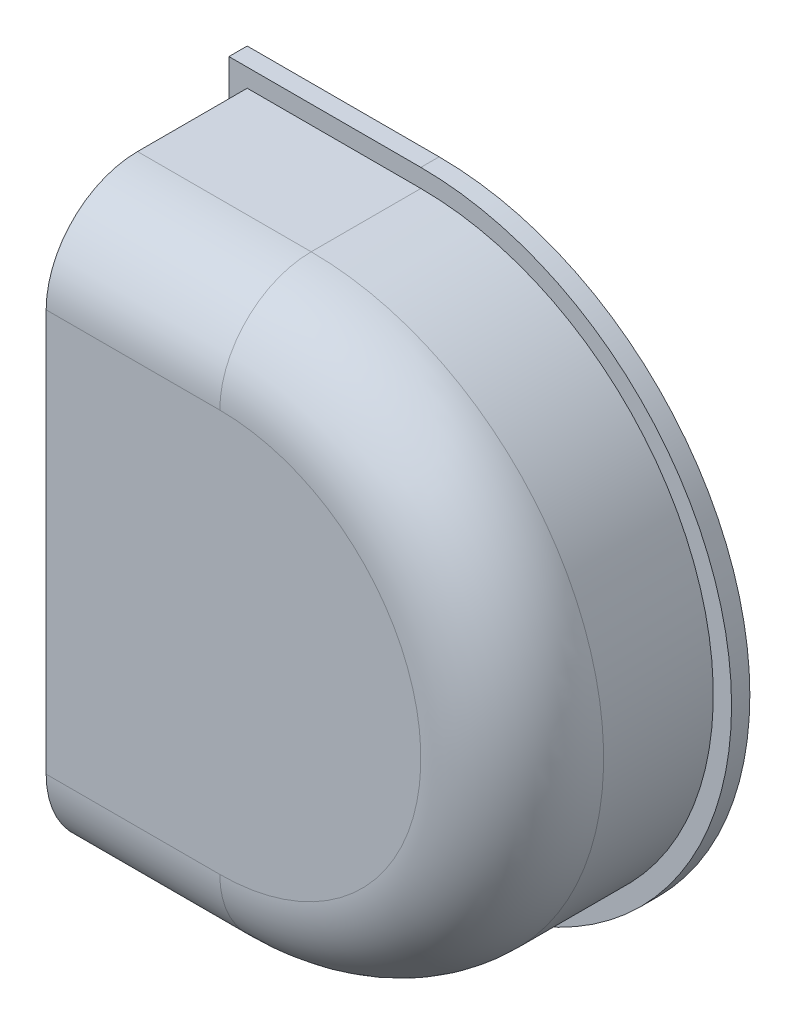
from build123d import *

# Parameters (mm, degrees)
BOSS_EXTRUDE3_DEPTH = 22
FILLET2_R           = 10
SHELL1_T            = -3
BOSS_EXTRUDE4_DEPTH = 2
SKETCH4_R           = 5
BOSS_EXTRUDE5_DEPTH = 11


with BuildPart() as part:
    # Sketch2 → Boss-Extrude3 (new body)
    with BuildSketch(Plane.XY):
        with BuildLine():
            Line((0, 0), (0, 64))
            Line((0, 64), (19, 64))
            ThreePointArc((19, 64), (51, 32), (19, 0))
            Line((19, 0), (0, 0))
        make_face()
    extrude(amount=BOSS_EXTRUDE3_DEPTH)

    # Fillet2
    fillet2_edges = [part.edges().sort_by_distance(p)[0] for p in [
        (9.5, 64, 22),
        (9.5, 0, 22),
        (51, 32, 22),
    ]]
    fillet(fillet2_edges, radius=FILLET2_R)

    # Shell1
    shell1_openings = [part.faces().sort_by_distance(p)[0] for p in [
        (17.5, 32, 0),
    ]]
    offset(amount=SHELL1_T, openings=shell1_openings, kind=Kind.INTERSECTION)

    # Sketch3 → Boss-Extrude4 (add)
    with BuildSketch(Plane(origin=(0, 0, 0), x_dir=(-1, 0, 0), z_dir=(0, 0, -1))):
        with BuildLine():
            Line((2, -2), (2, 66))
            Line((2, 66), (-19, 66))
            ThreePointArc((-19, 66), (-53, 32), (-19, -2))
            Line((-19, -2), (2, -2))
        make_face()
        with BuildLine():
            Line((-3, 3), (-3, 61))
            Line((-3, 61), (-19, 61))
            ThreePointArc((-19, 61), (-48, 32), (-19, 3))
            Line((-19, 3), (-3, 3))
        make_face(mode=Mode.SUBTRACT)
    extrude(amount=BOSS_EXTRUDE4_DEPTH)

    # Sketch4 → Boss-Extrude5 (add)
    with BuildSketch(Plane(origin=(0, 0, 19), x_dir=(-1, 0, 0), z_dir=(0, 0, -1))):
        with Locations((-19, 32)):
            Circle(SKETCH4_R)
    extrude(amount=BOSS_EXTRUDE5_DEPTH)


solid = part.part
